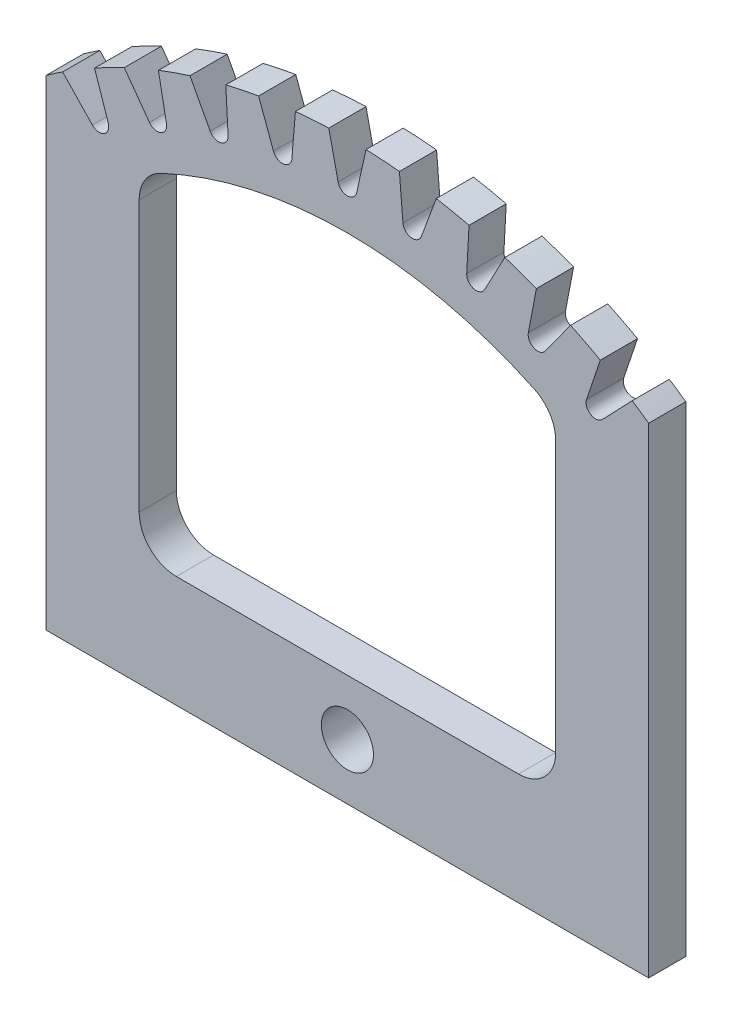
from build123d import *

# Parameters (mm, degrees)
ESQUISSE1_R        = 7
BOSS_EXTRU_2_DEPTH = 5


with BuildPart() as part:
    # Esquisse1 → Boss.-Extru.2 (new body, symmetric)
    with BuildSketch(Plane.XY):
        with BuildLine():
            Line((-81, 114.188440746), (-81, -15))
            Line((-81, -15), (81, -15))
            Line((81, -15), (81, 114.188440746))
            ThreePointArc((81, 114.188440746), (78.796472268, 115.719989449), (76.563994166, 117.209021825))
            Line((76.563994166, 117.209021825), (68.597490223, 108.845387152))
            ThreePointArc((68.597490223, 108.845387152), (65.420366542, 108.419035897), (64.316466092, 111.428569759))
            Line((64.316466092, 111.428569759), (68.001945903, 122.375387041))
            ThreePointArc((68.001945903, 122.375387041), (64.034003077, 124.497576081), (59.999908366, 126.491149872))
            Line((59.999908366, 126.491149872), (53.238382738, 117.126464015))
            ThreePointArc((53.238382738, 117.126464015), (50.148170341, 116.274127452), (48.64719318, 119.10661008))
            Line((48.64719318, 119.10661008), (50.81752925, 130.451442004))
            ThreePointArc((50.81752925, 130.451442004), (46.598920029, 132.017198319), (42.332170661, 133.446571058))
            Line((42.332170661, 133.446571058), (36.899996383, 123.253090169))
            ThreePointArc((36.899996383, 123.253090169), (33.953537336, 121.990446371), (32.083092779, 124.593776437))
            Line((32.083092779, 124.593776437), (32.698363453, 136.127943595))
            ThreePointArc((32.698363453, 136.127943595), (28.306685892, 137.10846631), (23.88576542, 137.947345789))
            Line((23.88576542, 137.947345789), (19.882863135, 127.112571065))
            ThreePointArc((19.882863135, 127.112571065), (17.134355274, 125.462845387), (14.928848702, 127.789136649))
            Line((14.928848702, 127.789136649), (13.977736553, 139.300476958))
            ThreePointArc((13.977736553, 139.300476958), (9.493772162, 139.677730115), (5, 139.910685796))
            Line((5, 139.910685796), (2.5, 128.633914537))
            ThreePointArc((2.5, 128.633914537), (0, 126.627452408), (-2.5, 128.633914537))
            Line((-2.5, 128.633914537), (-5, 139.910685796))
            ThreePointArc((-5, 139.910685796), (-9.493772162, 139.677730115), (-13.977736553, 139.300476958))
            Line((-13.977736553, 139.300476958), (-14.928848702, 127.789136649))
            ThreePointArc((-14.928848702, 127.789136649), (-17.134355274, 125.462845387), (-19.882863135, 127.112571065))
            Line((-19.882863135, 127.112571065), (-23.88576542, 137.947345789))
            ThreePointArc((-23.88576542, 137.947345789), (-28.306685892, 137.10846631), (-32.698363453, 136.127943595))
            Line((-32.698363453, 136.127943595), (-32.083092779, 124.593776437))
            ThreePointArc((-32.083092779, 124.593776437), (-33.953537336, 121.990446371), (-36.899996383, 123.253090169))
            Line((-36.899996383, 123.253090169), (-42.332170661, 133.446571058))
            ThreePointArc((-42.332170661, 133.446571058), (-46.598920029, 132.017198319), (-50.81752925, 130.451442004))
            Line((-50.81752925, 130.451442004), (-48.64719318, 119.10661008))
            ThreePointArc((-48.64719318, 119.10661008), (-50.148170341, 116.274127452), (-53.238382738, 117.126464015))
            Line((-53.238382738, 117.126464015), (-59.999908366, 126.491149872))
            ThreePointArc((-59.999908366, 126.491149872), (-64.034003077, 124.497576081), (-68.001945903, 122.375387041))
            Line((-68.001945903, 122.375387041), (-64.316466092, 111.428569759))
            ThreePointArc((-64.316466092, 111.428569759), (-65.420366542, 108.419035897), (-68.597490223, 108.845387152))
            Line((-68.597490223, 108.845387152), (-76.563994166, 117.209021825))
            ThreePointArc((-76.563994166, 117.209021825), (-78.796472268, 115.719989449), (-81, 114.188440746))
        make_face()
        Circle(ESQUISSE1_R, mode=Mode.SUBTRACT)
        with BuildLine():
            Line((-56, 97.713868002), (-56, 25))
            ThreePointArc((-56, 25), (-53.071067812, 17.928932188), (-46, 15))
            Line((-46, 15), (46, 15))
            ThreePointArc((46, 15), (53.071067812, 17.928932188), (56, 25))
            Line((56, 25), (56, 97.713868002))
            ThreePointArc((56, 97.713868002), (54.443713419, 103.071451759), (50.259259259, 106.761448373))
            ThreePointArc((50.259259259, 106.761448373), (0, 118), (-50.259259259, 106.761448373))
            ThreePointArc((-50.259259259, 106.761448373), (-54.443713419, 103.071451759), (-56, 97.713868002))
        make_face(mode=Mode.SUBTRACT)
    extrude(amount=BOSS_EXTRU_2_DEPTH, both=True)


solid = part.part
